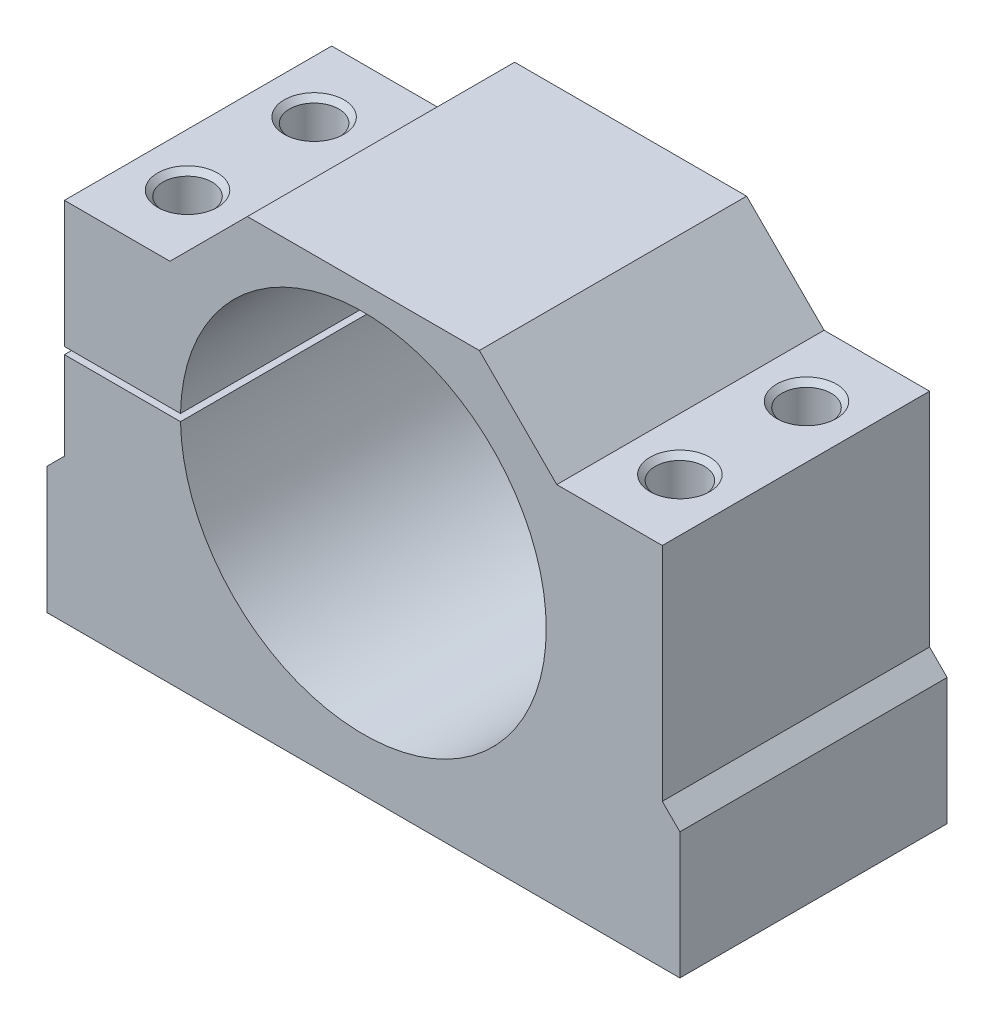
from build123d import *

# Parameters (mm, degrees)
AUFSATZ_LINEAR_AUSTRAGEN1_DEPTH          = 38
SKIZZE2_R                                = 26
SCHNITT_LINEAR_AUSTRAGEN1_DEPTH          = 38
SKIZZE3_W                                = 17
SKIZZE3_H                                = 1
SCHNITT_LINEAR_AUSTRAGEN2_DEPTH          = 38
F_7_0_7_DURCHMESSER_BOHRUNG4_D           = 7
F_7_0_7_DURCHMESSER_BOHRUNG4_CSINK_D     = 8.5
F_7_0_7_DURCHMESSER_BOHRUNG4_CSINK_ANGLE = 90


with BuildPart() as part:
    # Skizze1 → Aufsatz-Linear austragen1 (new body)
    with BuildSketch(Plane.XY):
        Polygon((0, 0), (0, 18), (2.5, 20.5), (2.5, 52), (17.5, 52), (28.51, 63.01), (61.49, 63.01), (72.5, 52), (87.5, 52), (87.5, 20.5), (90, 18), (90, 0), align=None)
    extrude(amount=AUFSATZ_LINEAR_AUSTRAGEN1_DEPTH)

    # Skizze2 → Schnitt-Linear austragen1 (cut)
    with BuildSketch(Plane.XY.offset(38)):
        with Locations((45, 33.5)):
            Circle(SKIZZE2_R)
    extrude(amount=-SCHNITT_LINEAR_AUSTRAGEN1_DEPTH, mode=Mode.SUBTRACT)

    # Skizze3 → Schnitt-Linear austragen2 (cut)
    with BuildSketch(Plane.XY.offset(38)):
        with Locations((11, 33.5)):
            Rectangle(SKIZZE3_W, SKIZZE3_H)
    extrude(amount=-SCHNITT_LINEAR_AUSTRAGEN2_DEPTH, mode=Mode.SUBTRACT)

    # Ø7.0 (7) Durchmesser Bohrung4 (through all)
    with Locations(Plane(origin=(0, 52, 0), x_dir=(1, 0, 0), z_dir=(0, 1, 0))):
        with Locations((10, -10), (10, -28), (80, -28), (80, -10)):
            CounterSinkHole(F_7_0_7_DURCHMESSER_BOHRUNG4_D / 2, F_7_0_7_DURCHMESSER_BOHRUNG4_CSINK_D / 2, counter_sink_angle=F_7_0_7_DURCHMESSER_BOHRUNG4_CSINK_ANGLE)


solid = part.part
